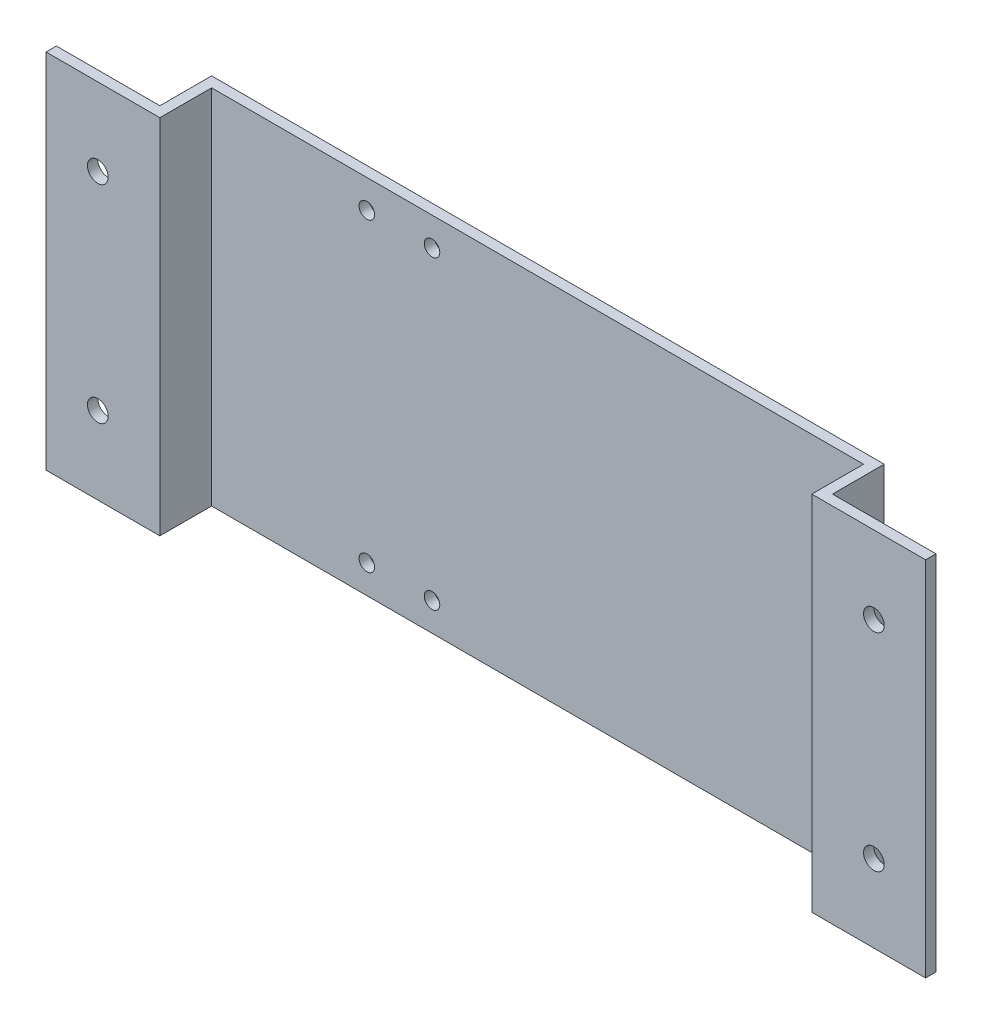
from build123d import *

# Parameters (mm, degrees)
SKETCH1_W           = 126
SKETCH1_H           = 70
BOSS_EXTRUDE1_DEPTH = 2
CUT_EXTRUDE1_REACH  = 4
SKETCH2_R           = 1.5
BOSS_EXTRUDE2_DEPTH = 70
CUT_EXTRUDE2_REACH  = 4
SKETCH4_R           = 2


with BuildPart() as part:
    # Sketch1 → Boss-Extrude1 (new body)
    with BuildSketch(Plane.XY):
        Rectangle(SKETCH1_W, SKETCH1_H)
    extrude(amount=BOSS_EXTRUDE1_DEPTH)

    # Sketch2 → Cut-Extrude1 (cut, up to next)
    with BuildSketch(Plane.XY.offset(2), mode=Mode.PRIVATE) as cut_extrude1_sk1:
        with Locations((-20.4, 29.5)):
            Circle(SKETCH2_R)
    cut_extrude1_tool1 = extrude(cut_extrude1_sk1.sketch, amount=-CUT_EXTRUDE1_REACH, mode=Mode.PRIVATE) & part.part
    add(cut_extrude1_tool1.solids().sort_by_distance((-20.4, 29.5, 2))[0], mode=Mode.SUBTRACT)
    # Sketch2 → Cut-Extrude1 (cut, up to next)
    with BuildSketch(Plane.XY.offset(2), mode=Mode.PRIVATE) as cut_extrude1_sk2:
        with Locations((-33, 29.5)):
            Circle(SKETCH2_R)
    cut_extrude1_tool2 = extrude(cut_extrude1_sk2.sketch, amount=-CUT_EXTRUDE1_REACH, mode=Mode.PRIVATE) & part.part
    add(cut_extrude1_tool2.solids().sort_by_distance((-33, 29.5, 2))[0], mode=Mode.SUBTRACT)
    # Sketch2 → Cut-Extrude1 (cut, up to next)
    with BuildSketch(Plane.XY.offset(2), mode=Mode.PRIVATE) as cut_extrude1_sk3:
        with Locations((-20.4, -29.5)):
            Circle(SKETCH2_R)
    cut_extrude1_tool3 = extrude(cut_extrude1_sk3.sketch, amount=-CUT_EXTRUDE1_REACH, mode=Mode.PRIVATE) & part.part
    add(cut_extrude1_tool3.solids().sort_by_distance((-20.4, -29.5, 2))[0], mode=Mode.SUBTRACT)
    # Sketch2 → Cut-Extrude1 (cut, up to next)
    with BuildSketch(Plane.XY.offset(2), mode=Mode.PRIVATE) as cut_extrude1_sk4:
        with Locations((-33, -29.5)):
            Circle(SKETCH2_R)
    cut_extrude1_tool4 = extrude(cut_extrude1_sk4.sketch, amount=-CUT_EXTRUDE1_REACH, mode=Mode.PRIVATE) & part.part
    add(cut_extrude1_tool4.solids().sort_by_distance((-33, -29.5, 2))[0], mode=Mode.SUBTRACT)

    # Sketch3 → Boss-Extrude2 (add)
    with BuildSketch(Plane(origin=(0, 35, 0), x_dir=(1, 0, 0), z_dir=(0, 1, 0))):
        Polygon((-63, 0), (-63, -12), (-85, -12), (-85, -10), (-65, -10), (-65, 0), align=None)
    boss_extrude2 = extrude(amount=-BOSS_EXTRUDE2_DEPTH)

    # Mirror1: Boss-Extrude2 across plane
    add(boss_extrude2.mirror(Plane(origin=(0, 0, 0), x_dir=(0, 0, 1), z_dir=(1, 0, 0))))

    # Sketch4 → Cut-Extrude2 (cut, up to next)
    with BuildSketch(Plane(origin=(0, 0, 10), x_dir=(-1, 0, 0), z_dir=(0, 0, -1)), mode=Mode.PRIVATE) as cut_extrude2_sk1:
        with Locations((-75, 20)):
            Circle(SKETCH4_R)
    cut_extrude2_tool1 = extrude(cut_extrude2_sk1.sketch, amount=-CUT_EXTRUDE2_REACH, mode=Mode.PRIVATE) & part.part
    add(cut_extrude2_tool1.solids().sort_by_distance((75, 20, 10))[0], mode=Mode.SUBTRACT)
    # Sketch4 → Cut-Extrude2 (cut, up to next)
    with BuildSketch(Plane(origin=(0, 0, 10), x_dir=(-1, 0, 0), z_dir=(0, 0, -1)), mode=Mode.PRIVATE) as cut_extrude2_sk2:
        with Locations((-75, -20)):
            Circle(SKETCH4_R)
    cut_extrude2_tool2 = extrude(cut_extrude2_sk2.sketch, amount=-CUT_EXTRUDE2_REACH, mode=Mode.PRIVATE) & part.part
    add(cut_extrude2_tool2.solids().sort_by_distance((75, -20, 10))[0], mode=Mode.SUBTRACT)
    # Sketch4 → Cut-Extrude2 (cut, up to next)
    with BuildSketch(Plane(origin=(0, 0, 10), x_dir=(-1, 0, 0), z_dir=(0, 0, -1)), mode=Mode.PRIVATE) as cut_extrude2_sk3:
        with Locations((75, 20)):
            Circle(SKETCH4_R)
    cut_extrude2_tool3 = extrude(cut_extrude2_sk3.sketch, amount=-CUT_EXTRUDE2_REACH, mode=Mode.PRIVATE) & part.part
    add(cut_extrude2_tool3.solids().sort_by_distance((-75, 20, 10))[0], mode=Mode.SUBTRACT)
    # Sketch4 → Cut-Extrude2 (cut, up to next)
    with BuildSketch(Plane(origin=(0, 0, 10), x_dir=(-1, 0, 0), z_dir=(0, 0, -1)), mode=Mode.PRIVATE) as cut_extrude2_sk4:
        with Locations((75, -20)):
            Circle(SKETCH4_R)
    cut_extrude2_tool4 = extrude(cut_extrude2_sk4.sketch, amount=-CUT_EXTRUDE2_REACH, mode=Mode.PRIVATE) & part.part
    add(cut_extrude2_tool4.solids().sort_by_distance((-75, -20, 10))[0], mode=Mode.SUBTRACT)


solid = part.part
